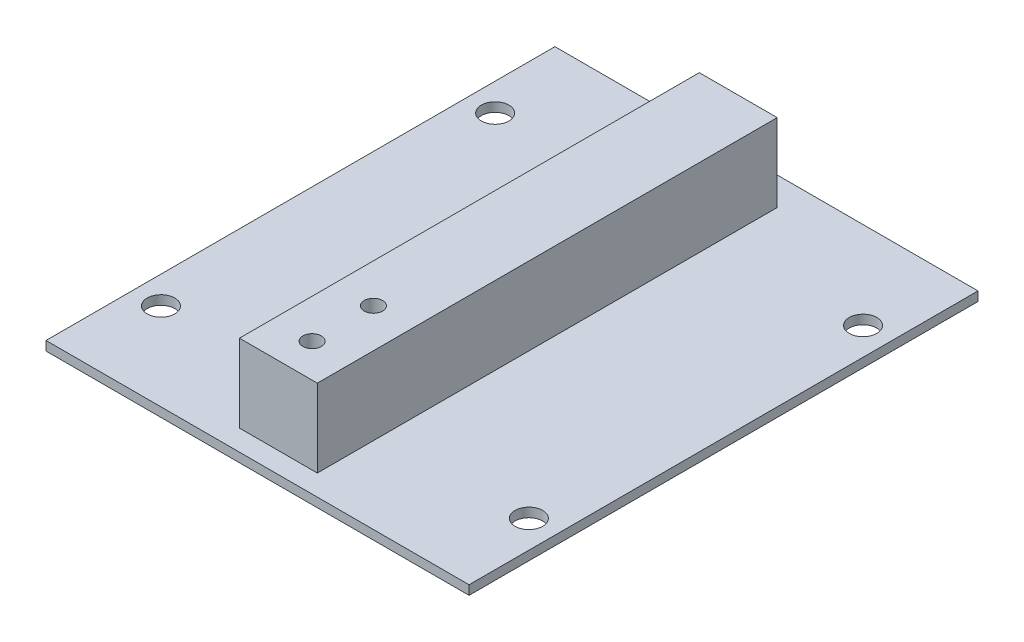
from build123d import *

# Parameters (mm, degrees)
SKETCH1_W           = 69
SKETCH1_H           = 83
SKETCH1_R           = 2.25
BOSS_EXTRUDE1_DEPTH = 1.5
SKETCH2_W           = 12.7
SKETCH2_H           = 75
SKETCH2_R           = 1.5
BOSS_EXTRUDE2_DEPTH = 12.7


with BuildPart() as part:
    # Sketch1 → Boss-Extrude1 (new body)
    with BuildSketch(Plane(origin=(0, 0, 0), x_dir=(1, 0, 0), z_dir=(0, 1, 0))):
        with Locations((34.5, 41.5)):
            Rectangle(SKETCH1_W, SKETCH1_H)
        with Locations((4.5, 68.75)):
            Circle(SKETCH1_R, mode=Mode.SUBTRACT)
        with Locations((64.5, 68.75)):
            Circle(SKETCH1_R, mode=Mode.SUBTRACT)
        with Locations((64.5, 14.25)):
            Circle(SKETCH1_R, mode=Mode.SUBTRACT)
        with Locations((4.5, 14.25)):
            Circle(SKETCH1_R, mode=Mode.SUBTRACT)
    extrude(amount=BOSS_EXTRUDE1_DEPTH)

    # Sketch2 → Boss-Extrude2 (add)
    with BuildSketch(Plane(origin=(0, 1.5, 0), x_dir=(1, 0, 0), z_dir=(0, 1, 0))):
        with Locations((34.5, 40.9)):
            Rectangle(SKETCH2_W, SKETCH2_H)
        with Locations((34.5, 8.9)):
            Circle(SKETCH2_R, mode=Mode.SUBTRACT)
        with Locations((34.5, 18.9)):
            Circle(SKETCH2_R, mode=Mode.SUBTRACT)
    extrude(amount=BOSS_EXTRUDE2_DEPTH)


solid = part.part
